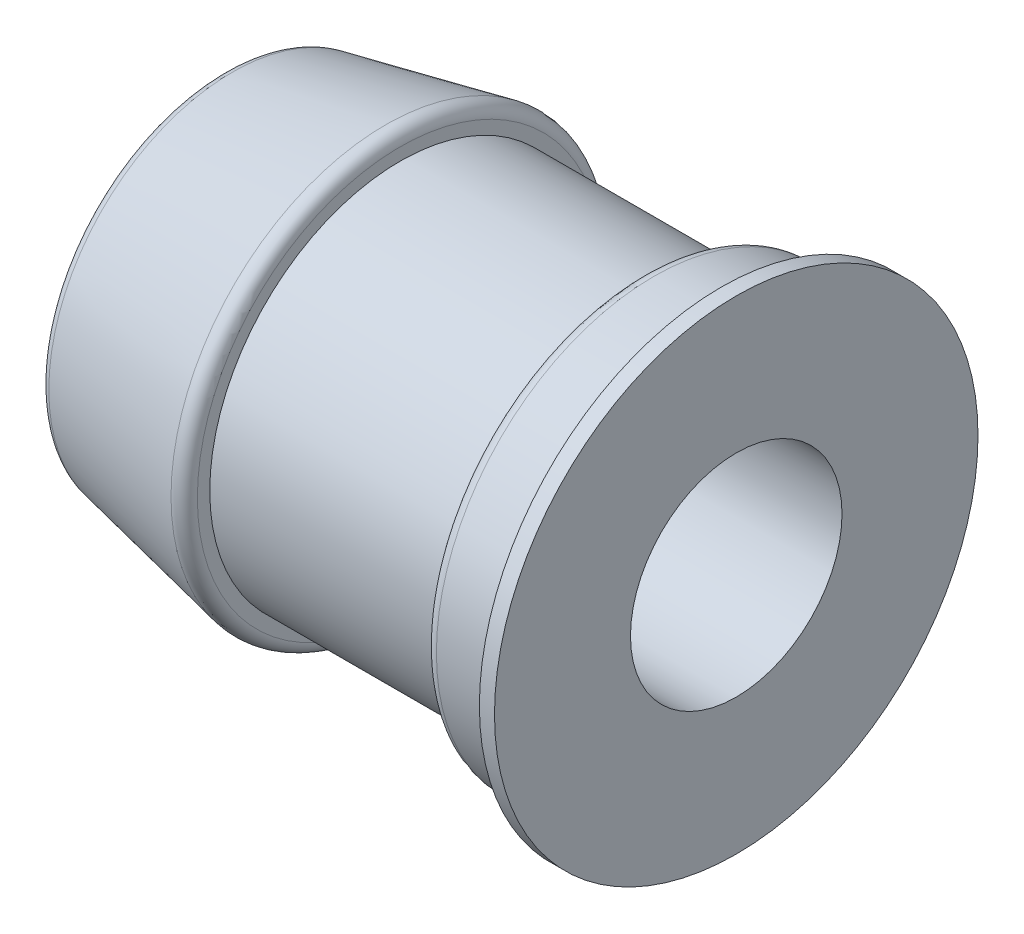
from build123d import *

# Parameters (mm, degrees)
FILLET1_R = 1.27


with BuildPart() as part:
    # Sketch1 → Revolve1 (revolve)
    with BuildSketch(Plane.XY):
        Polygon((0, 11.1125), (22.612386478, 11.1125), (22.612386478, 25.4), (21.024886478, 25.4), (19.558416794, 22.86), (12.7, 22.86), (12.7, 20), (-12.7, 20), (-12.7, 22.86), (-31.370233522, 19.05), (-31.370233522, 15.875), (0, 15.875), align=None)
    revolve(axis=Axis((-42.201018363, 0, 0), (1, 0, 0)))

    # Fillet1
    fillet1_edges = [part.edges().sort_by_distance(p)[0] for p in [
        (12.7, -22.86, 0),
        (-31.370233522, -19.05, 0),
        (-12.7, -22.86, 0),
    ]]
    fillet(fillet1_edges, radius=FILLET1_R)


solid = part.part
